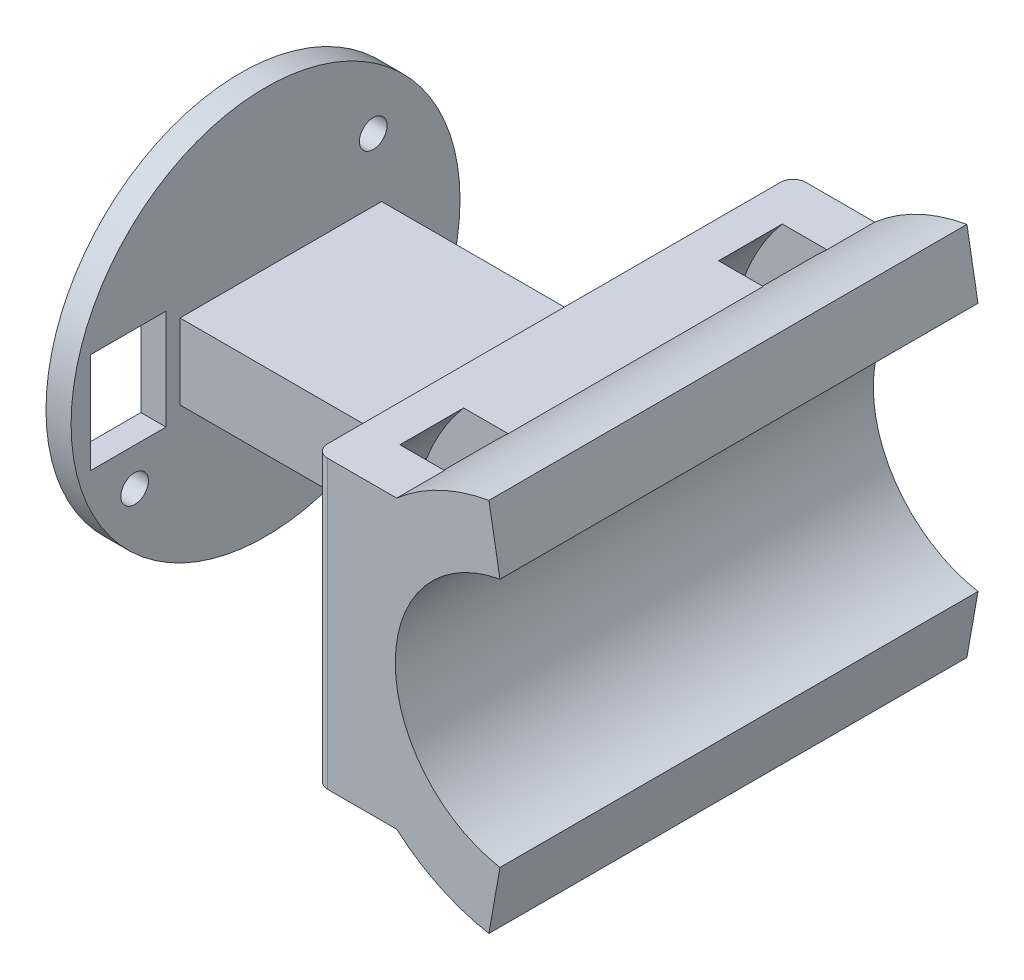
from build123d import *

# Parameters (mm, degrees)
BOSS_EXTRUDE1_DEPTH = 19.05
SKETCH6_W           = 16.071399664
SKETCH6_H           = 6
BOSS_EXTRUDE3_DEPTH = 23
SKETCH3_W           = 2.54
SKETCH3_H           = 5.08
SKETCH4_R           = 15.5
SKETCH4_R_2         = 1.099962386
SKETCH4_R_3         = 1.0993224
SKETCH4_W           = 8
SKETCH4_H           = 6
BOSS_EXTRUDE2_DEPTH = 2
FILLET1_R           = 1


with BuildPart() as part:
    # Sketch1 → Boss-Extrude1 (new, symmetric)
    with BuildSketch(Plane.XY):
        with BuildLine():
            Line((8.346153406, -9.946558305), (7.464020663, -14.949381691))
            ThreePointArc((7.464020663, -14.949381691), (3.546652059, -13.692553844), (0.110630651, -11.43))
            Line((0.110630651, -11.43), (-6.389369349, -11.43))
            Line((-6.389369349, -11.43), (-6.389369349, 11.43))
            Line((-6.389369349, 11.43), (0.110630651, 11.43))
            ThreePointArc((0.110630651, 11.43), (3.546652059, 13.692553844), (7.464020663, 14.949381691))
            Line((7.464020663, 14.949381691), (8.346153406, 9.946558305))
            ThreePointArc((8.346153406, 9.946558305), (0, 0), (8.346153406, -9.946558305))
        make_face()
    extrude(amount=BOSS_EXTRUDE1_DEPTH, both=True)

    # Sketch6 → Boss-Extrude3 (add)
    with BuildSketch(Plane.ZY.offset(6.389369349)):
        with Locations((-1.213689559, 0)):
            Rectangle(SKETCH6_W, SKETCH6_H)
    extrude(amount=BOSS_EXTRUDE3_DEPTH)

    # Sketch3 → Cut-Revolve1 (revolve, cut)
    with BuildSketch(Plane(origin=(0, 0, 0), x_dir=(1, 0, 0), z_dir=(0, 1, 0))):
        with Locations((-6.35, 12.7)):
            Rectangle(SKETCH3_W, SKETCH3_H)
        with Locations((-6.35, -12.7)):
            Rectangle(SKETCH3_W, SKETCH3_H)
    revolve(axis=Axis((10.1, 0, 19.05), (0, 0, -1)), mode=Mode.SUBTRACT)

    # Sketch4 → Boss-Extrude2 (add)
    with BuildSketch(Plane(origin=(-29.389369349, 0, 0), x_dir=(0, -1, 0), z_dir=(-1, 0, 0))):
        Circle(SKETCH4_R)
        with Locations((6.97426488, 10.435972737)):
            Circle(SKETCH4_R_2, mode=Mode.SUBTRACT)
        with Locations((-8.02573512, -8.580948715)):
            Circle(SKETCH4_R_3, mode=Mode.SUBTRACT)
        with Locations((-0.025715642, 10.93618237)):
            Rectangle(SKETCH4_W, SKETCH4_H, mode=Mode.SUBTRACT)
    extrude(amount=BOSS_EXTRUDE2_DEPTH)

    # Fillet1
    fillet1_edges = [part.edges().sort_by_distance(p)[0] for p in [
        (-6.389369349, 0, -19.05),
        (-6.389369349, 0, 19.05),
    ]]
    fillet(fillet1_edges, radius=FILLET1_R)


solid = part.part
